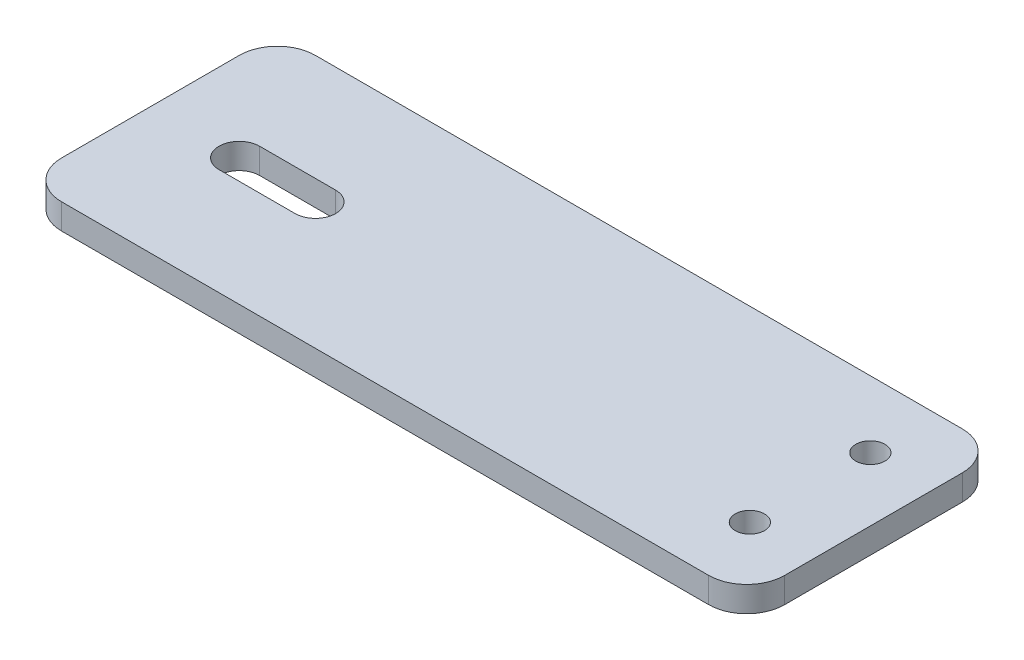
from build123d import *

# Parameters (mm, degrees)
SKETCH_1_R          = 1.6
SKETCH_1_R_2        = 1.15
EXTRUDE_1_DEPTH     = 2
FILLET_2_R          = 3
CUT_EXTRUDE_1_DEPTH = 10


with BuildPart() as part:
    # 草图1 → 凸台-拉伸1 (new body)
    with BuildSketch(Plane(origin=(0, 0, 0), x_dir=(1, 0, 0), z_dir=(0, 1, 0))):
        Polygon((-10, 10), (10, 10), (47, 10), (47, -10), (10, -10), (-10, -10), align=None)
        Circle(SKETCH_1_R, mode=Mode.SUBTRACT)
        with Locations((42, -4.75)):
            Circle(SKETCH_1_R_2, mode=Mode.SUBTRACT)
        with Locations((42, 4.75)):
            Circle(SKETCH_1_R_2, mode=Mode.SUBTRACT)
    extrude(amount=EXTRUDE_1_DEPTH)

    # 圆角2
    fillet_2_edges = [part.edges().sort_by_distance(p)[0] for p in [
        (-10, 1, -10),
        (47, 1, -10),
        (47, 1, 10),
        (-10, 1, 10),
    ]]
    fillet(fillet_2_edges, radius=FILLET_2_R)

    # 草图2 → 切除-拉伸1 (cut)
    with BuildSketch(Plane.XZ):
        with BuildLine():
            Line((-3, 1.6), (3, 1.6))
            ThreePointArc((3, 1.6), (4.6, 0), (3, -1.6))
            Line((3, -1.6), (-3, -1.6))
            ThreePointArc((-3, -1.6), (-4.6, 0), (-3, 1.6))
        make_face()
    extrude(amount=-CUT_EXTRUDE_1_DEPTH, mode=Mode.SUBTRACT)


solid = part.part
